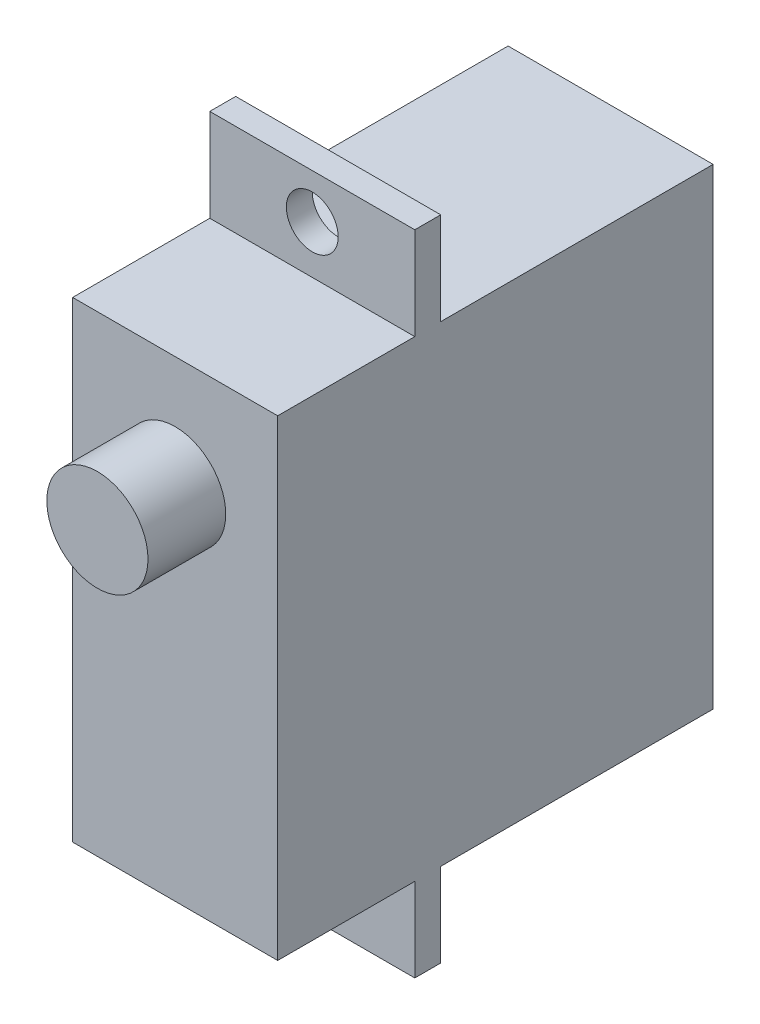
from build123d import *

# Parameters (mm, degrees)
SKETCH1_W           = 16.8
SKETCH1_H           = 18.2
BOSS_EXTRUDE1_DEPTH = 7.91
SKETCH2_W           = 1
SKETCH2_H           = 25
BOSS_EXTRUDE2_DEPTH = 7.91
SKETCH3_R           = 1
CUT_EXTRUDE1_DEPTH  = 21.9
SKETCH4_R           = 1.951580775
BOSS_EXTRUDE3_DEPTH = 3


with BuildPart() as part:
    # Sketch1 → Boss-Extrude1 (new body)
    with BuildSketch(Plane(origin=(0, 0, 0), x_dir=(0, 0, -1), z_dir=(1, 0, 0))):
        with Locations((-6.360008023, 6.524197801)):
            Rectangle(SKETCH1_W, SKETCH1_H)
    extrude(amount=BOSS_EXTRUDE1_DEPTH)

    # Sketch2 → Boss-Extrude2 (add)
    with BuildSketch(Plane(origin=(7.91, 0, 0), x_dir=(0, 0, -1), z_dir=(1, 0, 0))):
        with Locations((-8.970008023, 6.694520813)):
            Rectangle(SKETCH2_W, SKETCH2_H)
    extrude(amount=-BOSS_EXTRUDE2_DEPTH)

    # Sketch3 → Cut-Extrude1 (cut)
    with BuildSketch(Plane.XY.offset(9.470008023)):
        with Locations((3.955, 17.479197801)):
            Circle(SKETCH3_R)
        with Locations((3.955, -4.430802199)):
            Circle(SKETCH3_R)
    extrude(amount=-CUT_EXTRUDE1_DEPTH, mode=Mode.SUBTRACT)

    # Sketch4 → Boss-Extrude3 (add)
    with BuildSketch(Plane.XY.offset(14.760008023)):
        with Locations((3.955, 11.333194866)):
            Circle(SKETCH4_R)
    extrude(amount=BOSS_EXTRUDE3_DEPTH)


solid = part.part
